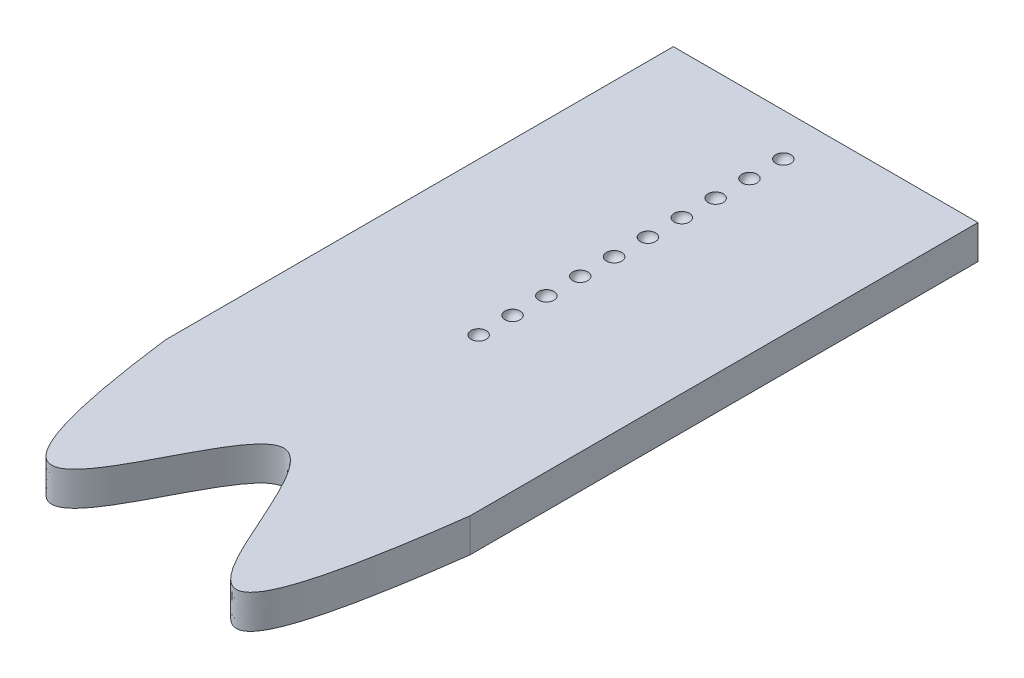
from build123d import *

# Parameters (mm, degrees)
BOSS_EXTRUDE1_DEPTH = 5.08
LPATTERN1_COUNT     = 10
LPATTERN1_PITCH     = 5.08


with BuildPart() as part:
    # Sketch1 → Boss-Extrude1 (new body)
    with BuildSketch(Plane(origin=(0, 0, 0), x_dir=(1, 0, 0), z_dir=(0, 1, 0))):
        with BuildLine():
            Line((-42.265392491, 3.812969283), (3.454607509, 3.812969283))
            Line((3.454607509, 3.812969283), (3.454607509, -72.387030717))
            add(Edge.make_bspline(
                [(-42.265392491, -72.387030717), (-35.611628709, -124.895548509), (-17.863111268, -27.582520746), (-4.18793222, -130.397350191), (3.454607509, -72.387030717)],
                knots=[0, 0, 0, 0, 0.483362267, 1, 1, 1, 1], degree=3))
            Line((-42.265392491, -72.387030717), (-42.265392491, 3.812969283))
        make_face()
    extrude(amount=BOSS_EXTRUDE1_DEPTH)

    # Sketch2 → Cut-Revolve1 (revolve, cut)
    with BuildSketch(Plane(origin=(0, 5.08, 0), x_dir=(1, 0, 0), z_dir=(0, 1, 0))):
        with BuildLine():
            Line((-20.548392491, -2.537030717), (-18.262392491, -2.537030717))
            ThreePointArc((-18.262392491, -2.537030717), (-19.405392491, -1.394030717), (-20.548392491, -2.537030717))
        make_face()
    cut_revolve1 = revolve(axis=Axis((-20.548392491, 5.08, 2.537030717), (1, 0, 0)), mode=Mode.SUBTRACT)

    # LPattern1: Cut-Revolve1 ×10
    with Locations(*[(0, 0, i * LPATTERN1_PITCH) for i in range(1, LPATTERN1_COUNT)]):
        add(cut_revolve1, mode=Mode.SUBTRACT)


solid = part.part
